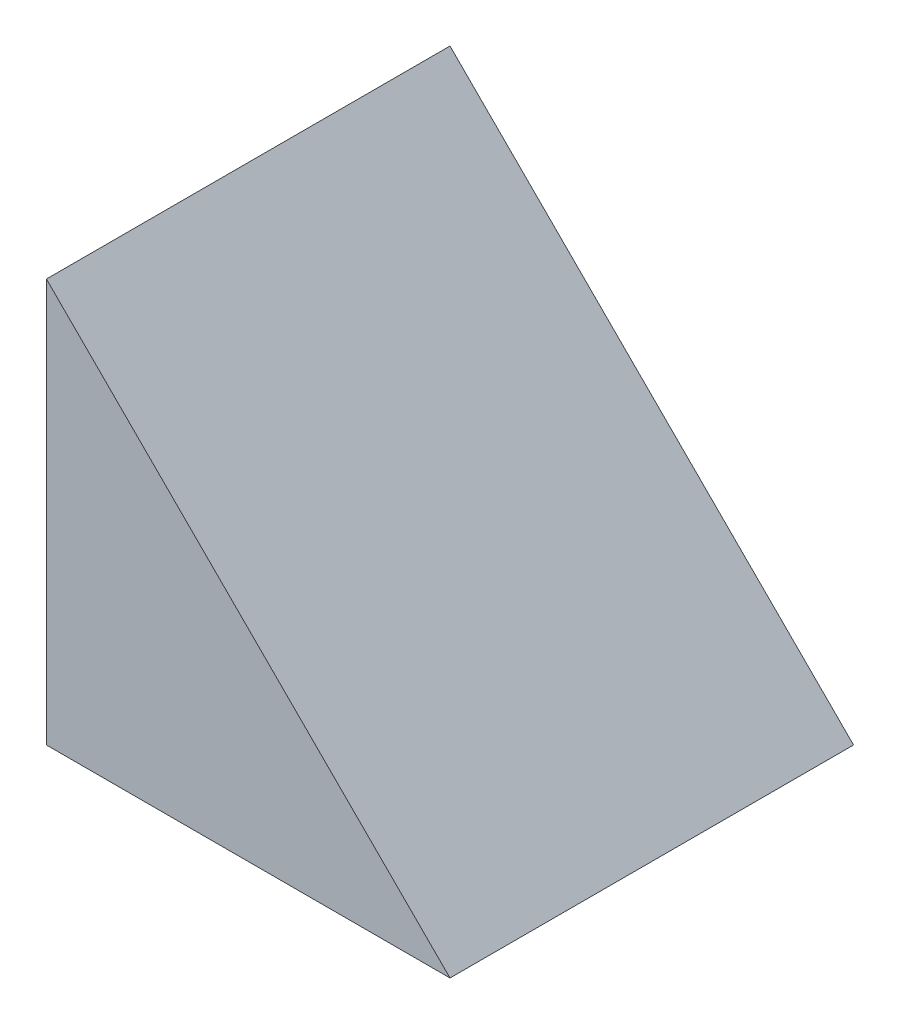
from build123d import *

# Parameters (mm, degrees)
BOSS_EXTRUDE1_DEPTH = 76.2


with BuildPart() as part:
    # Sketch1 → Boss-Extrude1 (new body)
    with BuildSketch(Plane.XY):
        Polygon((0, 76.2), (0, 0), (76.2, 0), align=None)
    extrude(amount=BOSS_EXTRUDE1_DEPTH)


solid = part.part
